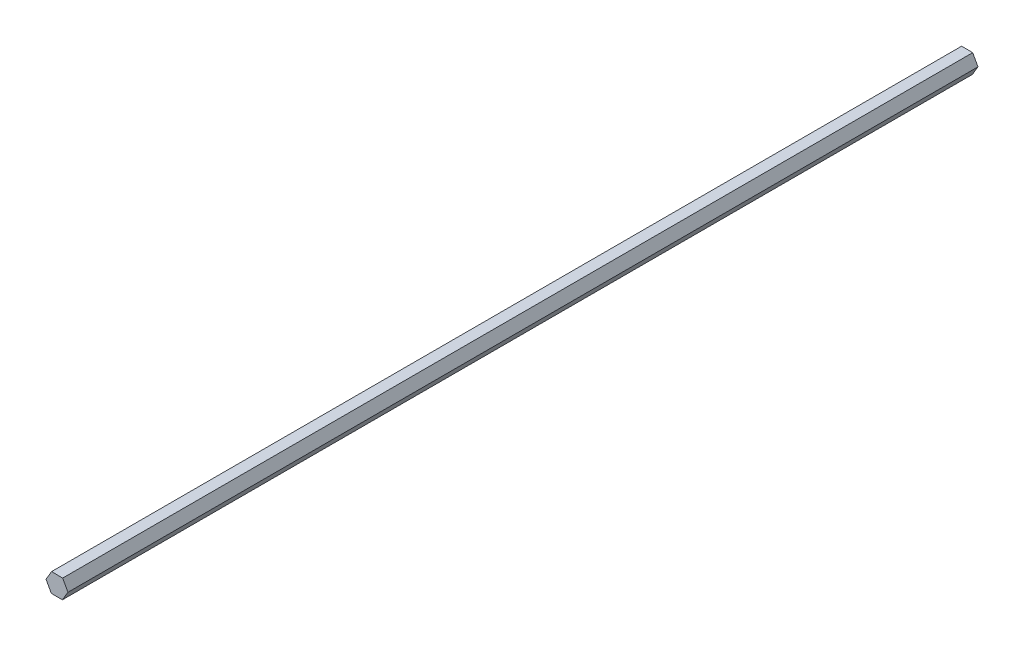
from build123d import *

# Parameters (mm, degrees)
BOSS_EXTRUDE1_DEPTH = 558.8


with BuildPart() as part:
    # Sketch2 → Boss-Extrude1 (new body)
    with BuildSketch(Plane.XY):
        Polygon((-0.072536491, -2.496194892), (3.3965214, 3.289770152), (0.120257632, 9.187044934), (-6.625064027, 9.298354673), (-10.094121918, 3.512389629), (-6.81785815, -2.384885153), align=None)
    extrude(amount=BOSS_EXTRUDE1_DEPTH)


solid = part.part
